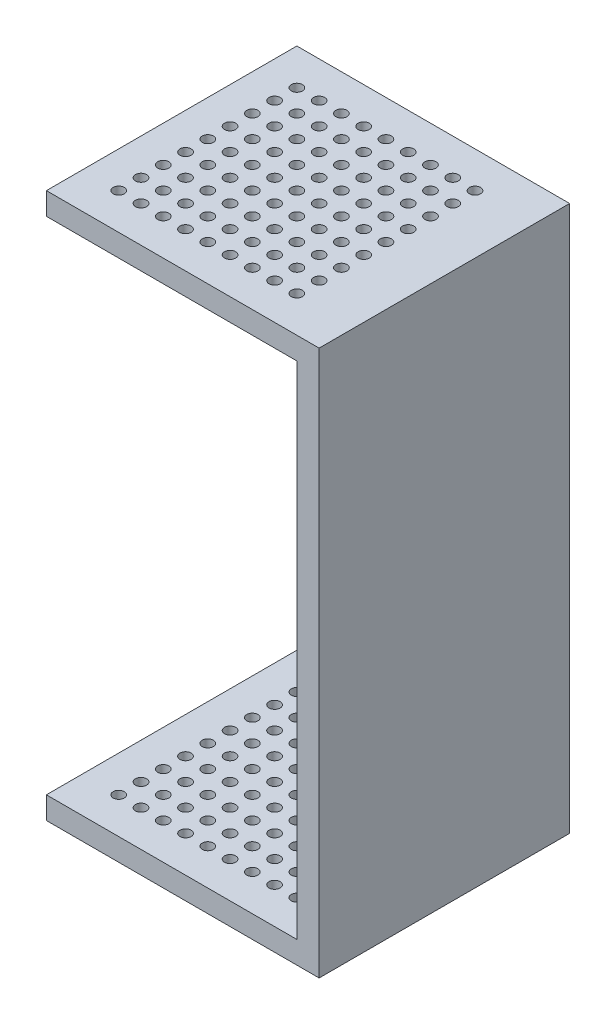
from build123d import *

# Parameters (mm, degrees)
SKETCH1_W           = 24.5
SKETCH1_H           = 22.5
BOSS_EXTRUDE1_DEPTH = 2
SKETCH2_W           = 2
SKETCH2_H           = 22.5
BOSS_EXTRUDE2_DEPTH = 45
SKETCH4_W           = 24.5
SKETCH4_H           = 22.5
BOSS_EXTRUDE3_DEPTH = 2
SKETCH3_R           = 0.5
CUT_EXTRUDE1_DEPTH  = 50


with BuildPart() as part:
    # Sketch1 → Boss-Extrude1 (new body)
    with BuildSketch(Plane(origin=(0, 0, 0), x_dir=(1, 0, 0), z_dir=(0, 1, 0))):
        Rectangle(SKETCH1_W, SKETCH1_H)
    extrude(amount=BOSS_EXTRUDE1_DEPTH)

    # Sketch2 → Boss-Extrude2 (add)
    with BuildSketch(Plane(origin=(0, 2, 0), x_dir=(1, 0, 0), z_dir=(0, 1, 0))):
        with Locations((11.25, 0)):
            Rectangle(SKETCH2_W, SKETCH2_H)
    extrude(amount=BOSS_EXTRUDE2_DEPTH)

    # Sketch4 → Boss-Extrude3 (add)
    with BuildSketch(Plane(origin=(0, 47, 0), x_dir=(1, 0, 0), z_dir=(0, 1, 0))):
        Rectangle(SKETCH4_W, SKETCH4_H)
    extrude(amount=BOSS_EXTRUDE3_DEPTH)

    # Sketch3 → Cut-Extrude1 (cut, through all)
    with BuildSketch(Plane.XZ):
        with Locations((-9, 8)):
            Circle(SKETCH3_R)
        with Locations((-7, 8)):
            Circle(SKETCH3_R)
        with Locations((-5, 8)):
            Circle(SKETCH3_R)
        with Locations((-3, 8)):
            Circle(SKETCH3_R)
        with Locations((-1, 8)):
            Circle(SKETCH3_R)
        with Locations((1, 8)):
            Circle(SKETCH3_R)
        with Locations((3, 8)):
            Circle(SKETCH3_R)
        with Locations((5, 8)):
            Circle(SKETCH3_R)
        with Locations((7, 8)):
            Circle(SKETCH3_R)
        with Locations((-7, 6)):
            Circle(SKETCH3_R)
        with Locations((-5, 6)):
            Circle(SKETCH3_R)
        with Locations((-3, 6)):
            Circle(SKETCH3_R)
        with Locations((-1, 6)):
            Circle(SKETCH3_R)
        with Locations((1, 6)):
            Circle(SKETCH3_R)
        with Locations((3, 6)):
            Circle(SKETCH3_R)
        with Locations((5, 6)):
            Circle(SKETCH3_R)
        with Locations((7, 6)):
            Circle(SKETCH3_R)
        with Locations((-7, 4)):
            Circle(SKETCH3_R)
        with Locations((-5, 4)):
            Circle(SKETCH3_R)
        with Locations((-3, 4)):
            Circle(SKETCH3_R)
        with Locations((-1, 4)):
            Circle(SKETCH3_R)
        with Locations((1, 4)):
            Circle(SKETCH3_R)
        with Locations((3, 4)):
            Circle(SKETCH3_R)
        with Locations((5, 4)):
            Circle(SKETCH3_R)
        with Locations((7, 4)):
            Circle(SKETCH3_R)
        with Locations((-7, 2)):
            Circle(SKETCH3_R)
        with Locations((-5, 2)):
            Circle(SKETCH3_R)
        with Locations((-3, 2)):
            Circle(SKETCH3_R)
        with Locations((-1, 2)):
            Circle(SKETCH3_R)
        with Locations((1, 2)):
            Circle(SKETCH3_R)
        with Locations((3, 2)):
            Circle(SKETCH3_R)
        with Locations((5, 2)):
            Circle(SKETCH3_R)
        with Locations((7, 2)):
            Circle(SKETCH3_R)
        with Locations((-7, 0)):
            Circle(SKETCH3_R)
        with Locations((-5, 0)):
            Circle(SKETCH3_R)
        with Locations((-3, 0)):
            Circle(SKETCH3_R)
        with Locations((-1, 0)):
            Circle(SKETCH3_R)
        with Locations((1, 0)):
            Circle(SKETCH3_R)
        with Locations((3, 0)):
            Circle(SKETCH3_R)
        with Locations((5, 0)):
            Circle(SKETCH3_R)
        with Locations((7, 0)):
            Circle(SKETCH3_R)
        with Locations((-7, -2)):
            Circle(SKETCH3_R)
        with Locations((-5, -2)):
            Circle(SKETCH3_R)
        with Locations((-3, -2)):
            Circle(SKETCH3_R)
        with Locations((-1, -2)):
            Circle(SKETCH3_R)
        with Locations((1, -2)):
            Circle(SKETCH3_R)
        with Locations((3, -2)):
            Circle(SKETCH3_R)
        with Locations((5, -2)):
            Circle(SKETCH3_R)
        with Locations((7, -2)):
            Circle(SKETCH3_R)
        with Locations((-7, -4)):
            Circle(SKETCH3_R)
        with Locations((-5, -4)):
            Circle(SKETCH3_R)
        with Locations((-3, -4)):
            Circle(SKETCH3_R)
        with Locations((-1, -4)):
            Circle(SKETCH3_R)
        with Locations((1, -4)):
            Circle(SKETCH3_R)
        with Locations((3, -4)):
            Circle(SKETCH3_R)
        with Locations((5, -4)):
            Circle(SKETCH3_R)
        with Locations((7, -4)):
            Circle(SKETCH3_R)
        with Locations((-7, -6)):
            Circle(SKETCH3_R)
        with Locations((-5, -6)):
            Circle(SKETCH3_R)
        with Locations((-3, -6)):
            Circle(SKETCH3_R)
        with Locations((-1, -6)):
            Circle(SKETCH3_R)
        with Locations((1, -6)):
            Circle(SKETCH3_R)
        with Locations((3, -6)):
            Circle(SKETCH3_R)
        with Locations((5, -6)):
            Circle(SKETCH3_R)
        with Locations((7, -6)):
            Circle(SKETCH3_R)
        with Locations((-7, -8)):
            Circle(SKETCH3_R)
        with Locations((-5, -8)):
            Circle(SKETCH3_R)
        with Locations((-3, -8)):
            Circle(SKETCH3_R)
        with Locations((-1, -8)):
            Circle(SKETCH3_R)
        with Locations((1, -8)):
            Circle(SKETCH3_R)
        with Locations((3, -8)):
            Circle(SKETCH3_R)
        with Locations((5, -8)):
            Circle(SKETCH3_R)
        with Locations((7, -8)):
            Circle(SKETCH3_R)
        with Locations((-9, 6)):
            Circle(SKETCH3_R)
        with Locations((-9, 4)):
            Circle(SKETCH3_R)
        with Locations((-9, 2)):
            Circle(SKETCH3_R)
        with Locations((-9, 0)):
            Circle(SKETCH3_R)
        with Locations((-9, -2)):
            Circle(SKETCH3_R)
        with Locations((-9, -4)):
            Circle(SKETCH3_R)
        with Locations((-9, -6)):
            Circle(SKETCH3_R)
        with Locations((-9, -8)):
            Circle(SKETCH3_R)
    extrude(amount=-CUT_EXTRUDE1_DEPTH, mode=Mode.SUBTRACT)


solid = part.part
